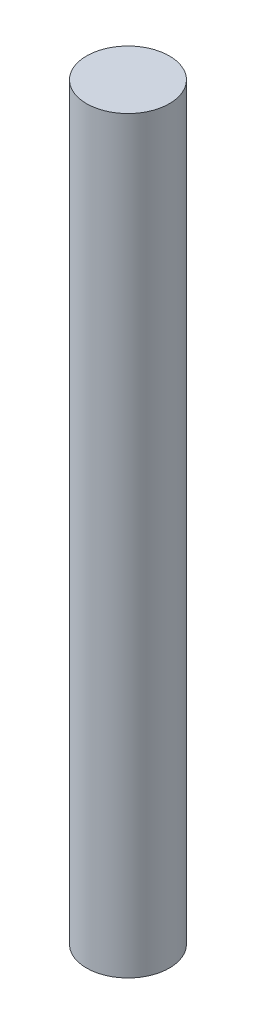
from build123d import *

# Parameters (mm, degrees)
SKETCH1_R           = 7.1875
BOSS_EXTRUDE1_DEPTH = 130


with BuildPart() as part:
    # Sketch1 → Boss-Extrude1 (new body)
    with BuildSketch(Plane(origin=(0, 0, 0), x_dir=(1, 0, 0), z_dir=(0, 1, 0))):
        Circle(SKETCH1_R)
    extrude(amount=BOSS_EXTRUDE1_DEPTH)


solid = part.part
